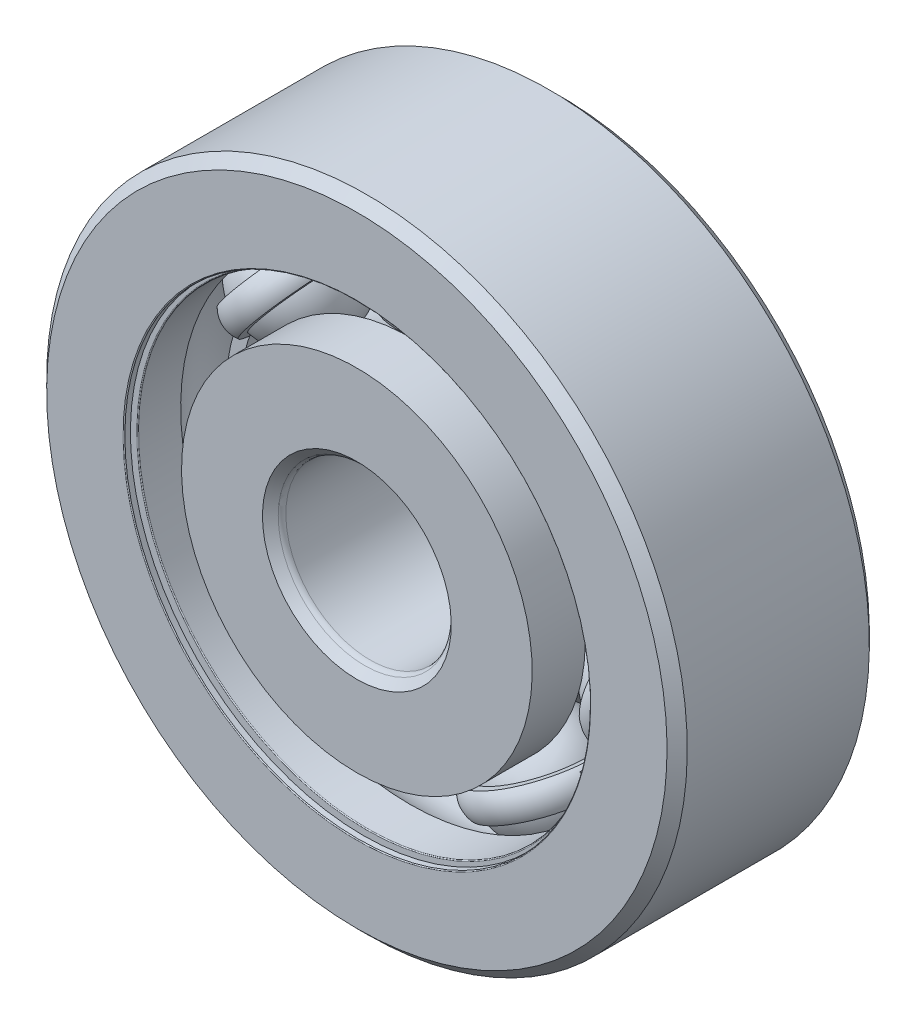
from build123d import *

# Parameters (mm, degrees)
BOSS_EXTRUDE1_DEPTH = 0.5
CIRPATTERN1_COUNT   = 7
CIRPATTERN2_COUNT   = 7
FILLET1_R           = 0.027
FILLET2_R           = 0.225


with BuildPart() as part:
    # Sketch3 → Revolve1 (revolve)
    with BuildSketch(Plane(origin=(0, 0, 0), x_dir=(0, 0, -1), z_dir=(1, 0, 0))):
        with BuildLine():
            Line((2.7, 9.5), (3, 9.2))
            Line((3, 9.2), (3, 6.8))
            Line((3, 6.8), (1.425, 6.8))
            ThreePointArc((1.425, 6.8), (0, 7.6342047), (-1.425, 6.8))
            Line((-1.425, 6.8), (-3, 6.8))
            Line((-3, 6.8), (-3, 9.2))
            Line((-3, 9.2), (-2.7, 9.5))
            Line((-2.7, 9.5), (2.7, 9.5))
        make_face()
    revolve(axis=Axis((0, 0, 3), (0, 0, -1)))

    # Sketch8 → Cut-Revolve1 (revolve, cut)
    with BuildSketch(Plane(origin=(0, 0, 0), x_dir=(0, 0, -1), z_dir=(1, 0, 0))):
        Polygon((-2.808, 6.8), (-2.7, 6.8), (-2.7, 7.7), (-2.808, 7.7), (-2.808, 6.908), (-3, 6.908), (-3, 6.8), align=None)
        Polygon((2.7, 6.8), (2.808, 6.8), (3, 6.8), (3, 6.908), (2.808, 6.908), (2.808, 7.7), (2.7, 7.7), align=None)
    revolve(axis=Axis((0, 0, 3), (0, 0, -1)), mode=Mode.SUBTRACT)

    # Fillet1
    fillet1_edges = [part.edges().sort_by_distance(p)[0] for p in [
        (0, -6.908, 3),
        (0, -6.8, 2.7),
        (0, -6.908, -3),
        (0, -6.8, -2.7),
    ]]
    fillet(fillet1_edges, radius=FILLET1_R)


with BuildPart() as body_2:
    # Sketch4 → Revolve2 (revolve)
    with BuildSketch(Plane(origin=(0, 0, 0), x_dir=(0, 0, -1), z_dir=(1, 0, 0))):
        with BuildLine():
            Line((-2.7, 2.5), (-3, 2.8))
            Line((-3, 2.8), (-3, 5.2))
            Line((-3, 5.2), (-1.425, 5.2))
            ThreePointArc((-1.425, 5.2), (0, 4.3657953), (1.425, 5.2))
            Line((1.425, 5.2), (3, 5.2))
            Line((3, 5.2), (3, 2.8))
            Line((3, 2.8), (2.7, 2.5))
            Line((2.7, 2.5), (-2.7, 2.5))
        make_face()
    revolve(axis=Axis((0, 0, 3), (0, 0, -1)))

    # Fillet2
    fillet2_edges = [body_2.edges().sort_by_distance(p)[0] for p in [
        (0, -2.5, 2.7),
        (0, -2.5, -2.7),
    ]]
    fillet(fillet2_edges, radius=FILLET2_R)


with BuildPart() as body_3:
    # Sketch5 → Revolve3 (revolve)
    with BuildSketch(Plane(origin=(0, 0, 0), x_dir=(0, 0, -1), z_dir=(1, 0, 0))):
        with BuildLine():
            Line((-1.6342047, 6), (1.6342047, 6))
            ThreePointArc((1.6342047, 6), (0, 7.6342047), (-1.6342047, 6))
        make_face()
    revolve(axis=Axis((0, 6, 1.6342047), (0, 0, -1)))


with BuildPart() as body_4:
    # Sketch6 → Revolve4 (revolve)
    with BuildSketch(Plane(origin=(0, 0, 0), x_dir=(0, 0, -1), z_dir=(1, 0, 0))):
        with BuildLine():
            Line((-1.584495188, 6.4), (-1.820412656, 6.4))
            ThreePointArc((-1.820412656, 6.4), (-1.938371391, 6), (-1.820412656, 5.6))
            Line((-1.820412656, 5.6), (-1.584495188, 5.6))
            ThreePointArc((-1.584495188, 5.6), (-1.6342047, 6), (-1.584495188, 6.4))
        make_face()
    revolve4 = revolve(axis=Axis((0, 9.5, 0), (0, -1, 0)))

    # Sketch7 → Boss-Extrude1 (add, symmetric)
    with BuildSketch(Plane.XY):
        with BuildLine():
            Line((4.690988895, 3.740938811), (5.003721488, 3.990334732))
            ThreePointArc((5.003721488, 3.990334732), (2.77685593, 5.766200755), (0, 6.4))
            Line((0, 6.4), (0, 6))
            ThreePointArc((0, 6), (2.603302435, 5.405813207), (4.690988895, 3.740938811))
        make_face()
    boss_extrude1 = extrude(amount=BOSS_EXTRUDE1_DEPTH, both=True)

    # CirPattern2: Revolve4, Boss-Extrude1 ×7 about axis
    cirpattern2_axis = Axis((0, 0, 0), (0, 0, 1))
    for i in range(1, CIRPATTERN2_COUNT):
        add(revolve4.rotate(cirpattern2_axis, i * 360 / CIRPATTERN2_COUNT))
        add(boss_extrude1.rotate(cirpattern2_axis, i * 360 / CIRPATTERN2_COUNT))


with BuildPart() as cirpattern1_1:
    # CirPattern1: pattern copy
    add(body_3.part.rotate(Axis((0, 0, 0), (0, 0, 1)), 1 * 360 / CIRPATTERN1_COUNT))


with BuildPart() as cirpattern1_2:
    # CirPattern1: pattern copy
    add(body_3.part.rotate(Axis((0, 0, 0), (0, 0, 1)), 2 * 360 / CIRPATTERN1_COUNT))


with BuildPart() as cirpattern1_3:
    # CirPattern1: pattern copy
    add(body_3.part.rotate(Axis((0, 0, 0), (0, 0, 1)), 3 * 360 / CIRPATTERN1_COUNT))


with BuildPart() as cirpattern1_4:
    # CirPattern1: pattern copy
    add(body_3.part.rotate(Axis((0, 0, 0), (0, 0, 1)), 4 * 360 / CIRPATTERN1_COUNT))


with BuildPart() as cirpattern1_5:
    # CirPattern1: pattern copy
    add(body_3.part.rotate(Axis((0, 0, 0), (0, 0, 1)), 5 * 360 / CIRPATTERN1_COUNT))


with BuildPart() as cirpattern1_6:
    # CirPattern1: pattern copy
    add(body_3.part.rotate(Axis((0, 0, 0), (0, 0, 1)), 6 * 360 / CIRPATTERN1_COUNT))


solid = Compound([part.part, body_2.part, body_3.part, body_4.part, cirpattern1_1.part, cirpattern1_2.part, cirpattern1_3.part, cirpattern1_4.part, cirpattern1_5.part, cirpattern1_6.part])
